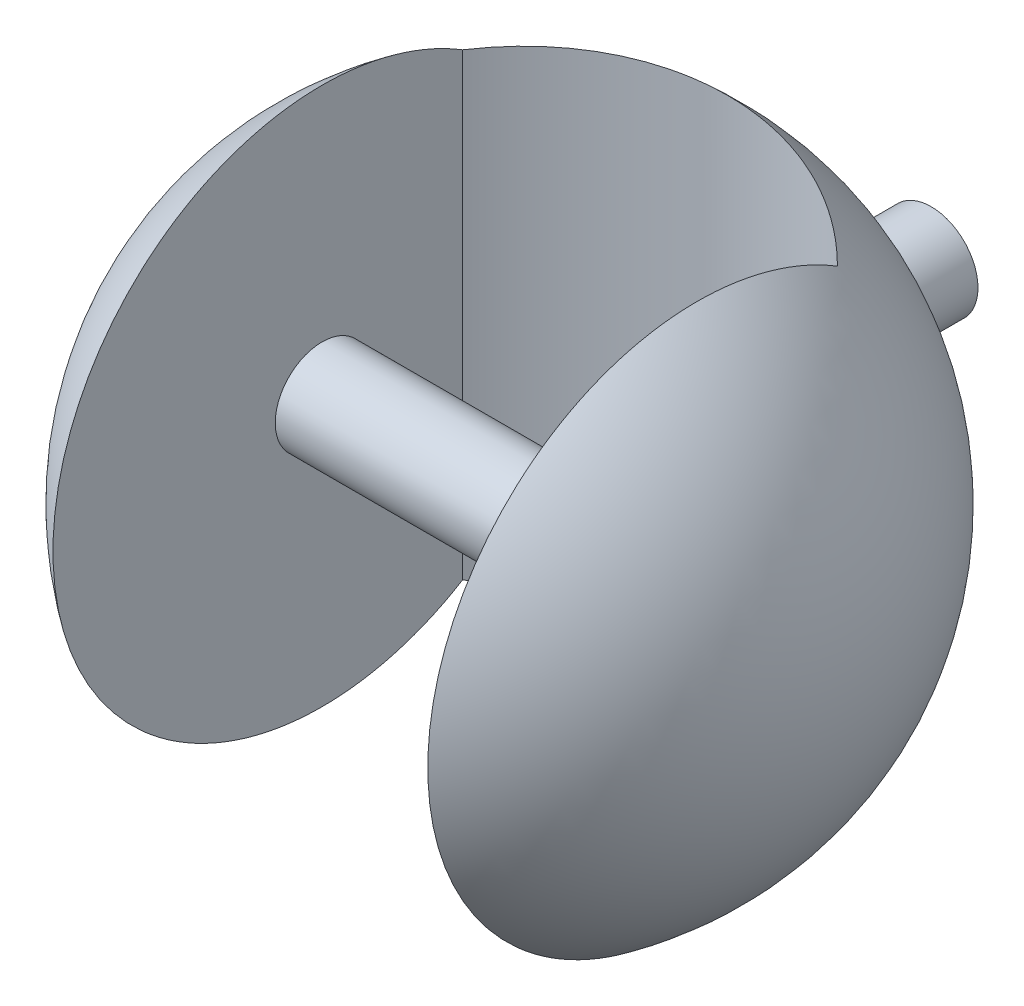
from build123d import *

# Parameters (mm, degrees)
SKETCH4_W               = 80
SKETCH4_H               = 100
CUT_EXTRUDE1_DEPTH      = 200
CUT_EXTRUDE1_DEPTH_BACK = 200
SKETCH5_R               = 10
BOSS_EXTRUDE1_DEPTH     = 60
SKETCH6_R               = 10
BOSS_EXTRUDE2_DEPTH     = 80
CUT_EXTRUDE2_DEPTH      = 64.245553203
CUT_EXTRUDE2_DEPTH_BACK = 64.245553203


with BuildPart() as part:
    # Sketch3 → Revolve1 (revolve)
    with BuildSketch(Plane.XY):
        with BuildLine():
            Line((0, 70), (0, -70))
            ThreePointArc((0, -70), (70, 0), (0, 70))
        make_face()
    revolve(axis=Axis((0, 136.094420601, 0), (0, -1, 0)))

    # Sketch4 → Cut-Extrude1 (cut, two sides)
    with BuildSketch(Plane(origin=(0, 0, 0), x_dir=(1, 0, 0), z_dir=(0, 1, 0))) as cut_extrude1_sk:
        with Locations((0, -20)):
            Rectangle(SKETCH4_W, SKETCH4_H)
    extrude(amount=CUT_EXTRUDE1_DEPTH, mode=Mode.SUBTRACT)
    extrude(cut_extrude1_sk.sketch, amount=-CUT_EXTRUDE1_DEPTH_BACK, mode=Mode.SUBTRACT)

    # Sketch5 → Boss-Extrude1 (add)
    with BuildSketch(Plane.XY.offset(-30)):
        Circle(SKETCH5_R)
    extrude(amount=-BOSS_EXTRUDE1_DEPTH)

    # Sketch6 → Boss-Extrude2 (add)
    with BuildSketch(Plane(origin=(-40, 0, 0), x_dir=(0, 0, -1), z_dir=(1, 0, 0))):
        Circle(SKETCH6_R)
    extrude(amount=BOSS_EXTRUDE2_DEPTH)

    # Sketch7 → Cut-Extrude2 (cut, two sides)
    with BuildSketch(Plane(origin=(0, 0, 0), x_dir=(1, 0, 0), z_dir=(0, 1, 0))) as cut_extrude2_sk:
        with BuildLine():
            Line((40, 30), (-40, 30))
            ThreePointArc((-40, 30), (0, 46.568542495), (40, 30))
        make_face()
    extrude(amount=CUT_EXTRUDE2_DEPTH, mode=Mode.SUBTRACT)
    extrude(cut_extrude2_sk.sketch, amount=-CUT_EXTRUDE2_DEPTH_BACK, mode=Mode.SUBTRACT)


solid = part.part
